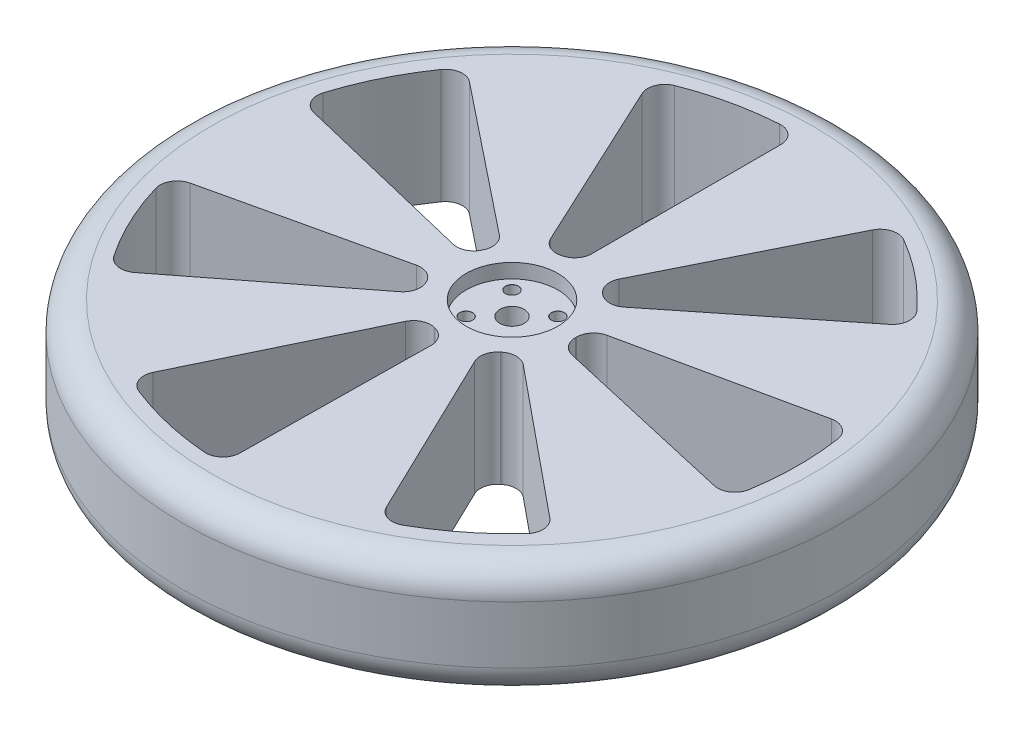
from build123d import *

# Parameters (mm, degrees)
SKETCH1_R                      = 115
BOSS_EXTRUDE1_DEPTH            = 40
CUT_EXTRUDE1_DEPTH             = 40
FILLET1_R                      = 6
SKETCH3_R                      = 4.25
CUT_EXTRUDE2_DEPTH             = 40
CIRPATTERN1_COUNT              = 7
FILLET1_OF_CIRPATTERN1_R       = 6
SKETCH4_R                      = 16
CUT_EXTRUDE3_DEPTH             = 5
M4_CLEARANCE_HOLE1_D           = 4.5
M4_CLEARANCE_HOLE1_DEPTH       = 13
M4_CLEARANCE_HOLE1_CSINK_D     = 4.55
M4_CLEARANCE_HOLE1_CSINK_ANGLE = 90
M4_CLEARANCE_HOLE1_TIP         = 1.351936393
FILLET2_R                      = 10


with BuildPart() as part:
    # Sketch1 → Boss-Extrude1 (new body)
    with BuildSketch(Plane(origin=(0, 0, 0), x_dir=(1, 0, 0), z_dir=(0, 1, 0))):
        Circle(SKETCH1_R)
    extrude(amount=BOSS_EXTRUDE1_DEPTH)

    # Sketch2 → Cut-Extrude1 (cut)
    with BuildSketch(Plane(origin=(0, 40, 0), x_dir=(1, 0, 0), z_dir=(0, 1, 0))):
        with BuildLine():
            ThreePointArc((-9.508910889, 20.391925208), (-4.869891314, 21.96666016), (0, 22.5))
            Line((0, 22.5), (0, 100))
            ThreePointArc((0, 100), (-21.643961394, 97.629600712), (-42.261826174, 90.630778704))
            Line((-42.261826174, 90.630778704), (-9.508910889, 20.391925208))
        make_face()
    cut_extrude1 = extrude(amount=-CUT_EXTRUDE1_DEPTH, mode=Mode.SUBTRACT)

    # Fillet1
    fillet1_edges = [part.edges().sort_by_distance(p)[0] for p in [
        (0, 20, -22.5),
        (-9.508910889, 20, -20.391925208),
        (-42.261826174, 20, -90.630778704),
        (0, 20, -100),
    ]]
    fillet(fillet1_edges, radius=FILLET1_R)

    # Sketch3 → Cut-Extrude2 (cut)
    with BuildSketch(Plane(origin=(0, 40, 0), x_dir=(1, 0, 0), z_dir=(0, 1, 0))):
        Circle(SKETCH3_R)
    extrude(amount=-CUT_EXTRUDE2_DEPTH, mode=Mode.SUBTRACT)

    # CirPattern1: Cut-Extrude1 ×7 about axis
    cirpattern1_axis = Axis((0, 0, 0), (0, 1, 0))
    for i in range(1, CIRPATTERN1_COUNT):
        add(cut_extrude1.rotate(cirpattern1_axis, i * 360 / CIRPATTERN1_COUNT), mode=Mode.SUBTRACT)

    # Fillet1 of CirPattern1
    fillet1_of_cirpattern1_edges = [part.edges().sort_by_distance(p)[0] for p in [
        (-17.591208356, 20, -14.028520542),
        (-21.871758082, 20, -5.279791511),
        (-97.207813699, 20, -23.465740047),
        (-78.183148247, 20, -62.348980186),
        (-21.935878024, 20, 5.006721014),
        (-17.764725337, 20, 13.808132883),
        (-78.95433483, 20, 61.369479479),
        (-97.492791218, 20, 22.252093396),
        (-9.76238413, 20, 20.271799528),
        (-0.280492078, 20, 22.498251581),
        (-1.24663146, 20, 99.992229248),
        (-43.388373912, 20, 90.09688679),
        (9.76238413, 20, 20.271799528),
        (17.414957436, 20, 14.246727958),
        (77.399810827, 20, 63.318790923),
        (43.388373912, 20, 90.09688679),
        (21.935878024, 20, 5.006721014),
        (21.996588801, 20, -4.732872398),
        (97.762616892, 20, -21.034988435),
        (97.492791218, 20, 22.252093396),
        (17.591208356, 20, -14.028520542),
        (10.01434015, 20, -20.148523305),
        (44.508178444, 20, -89.548992466),
        (78.183148247, 20, -62.348980186),
    ]]
    fillet(fillet1_of_cirpattern1_edges, radius=FILLET1_OF_CIRPATTERN1_R)

    # Sketch4 → Cut-Extrude3 (cut)
    with BuildSketch(Plane(origin=(0, 40, 0), x_dir=(1, 0, 0), z_dir=(0, 1, 0))):
        Circle(SKETCH4_R)
    extrude(amount=-CUT_EXTRUDE3_DEPTH, mode=Mode.SUBTRACT)

    # M4 Clearance Hole1
    with Locations(Plane(origin=(0, 35, 0), x_dir=(1, 0, 0), z_dir=(0, 1, 0))):
        with Locations((8, 8), (-8, 8), (-8, -8), (8, -8)):
            CounterSinkHole(M4_CLEARANCE_HOLE1_D / 2, M4_CLEARANCE_HOLE1_CSINK_D / 2, depth=M4_CLEARANCE_HOLE1_DEPTH, counter_sink_angle=M4_CLEARANCE_HOLE1_CSINK_ANGLE)
            with Locations((0, 0, -(M4_CLEARANCE_HOLE1_DEPTH + M4_CLEARANCE_HOLE1_TIP / 2))):  # 118° drill point
                Cone(0, M4_CLEARANCE_HOLE1_D / 2, M4_CLEARANCE_HOLE1_TIP, mode=Mode.SUBTRACT)

    # Fillet2
    fillet2_edges = [part.edges().sort_by_distance(p)[0] for p in [
        (-115, 0, 0),
        (-115, 40, 0),
    ]]
    fillet(fillet2_edges, radius=FILLET2_R)


solid = part.part
